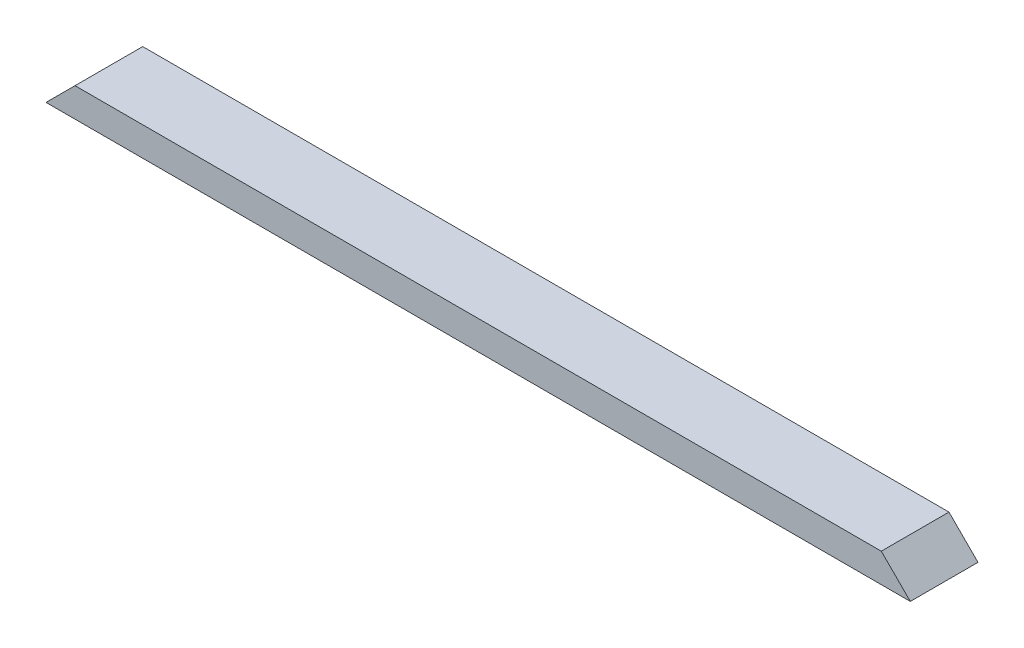
from build123d import *

# Parameters (mm, degrees)
SKETCH1_W           = 1135.0371
SKETCH1_H           = 88.9
BOSS_EXTRUDE1_DEPTH = 38.1
CUT_EXTRUDE1_DEPTH  = 89.9


with BuildPart() as part:
    # Sketch1 → Boss-Extrude1 (new body)
    with BuildSketch(Plane(origin=(0, 0, 0), x_dir=(1, 0, 0), z_dir=(0, 1, 0))):
        with Locations((567.51855, 44.45)):
            Rectangle(SKETCH1_W, SKETCH1_H)
    extrude(amount=BOSS_EXTRUDE1_DEPTH)

    # Sketch2 → Cut-Extrude1 (cut, through all)
    with BuildSketch(Plane.XY):
        Polygon((0, 0), (38.1, 38.1), (0, 38.1), align=None)
        Polygon((1135.0371, 0), (1135.0371, 38.1), (1096.9371, 38.1), align=None)
    extrude(amount=-CUT_EXTRUDE1_DEPTH, mode=Mode.SUBTRACT)


solid = part.part
